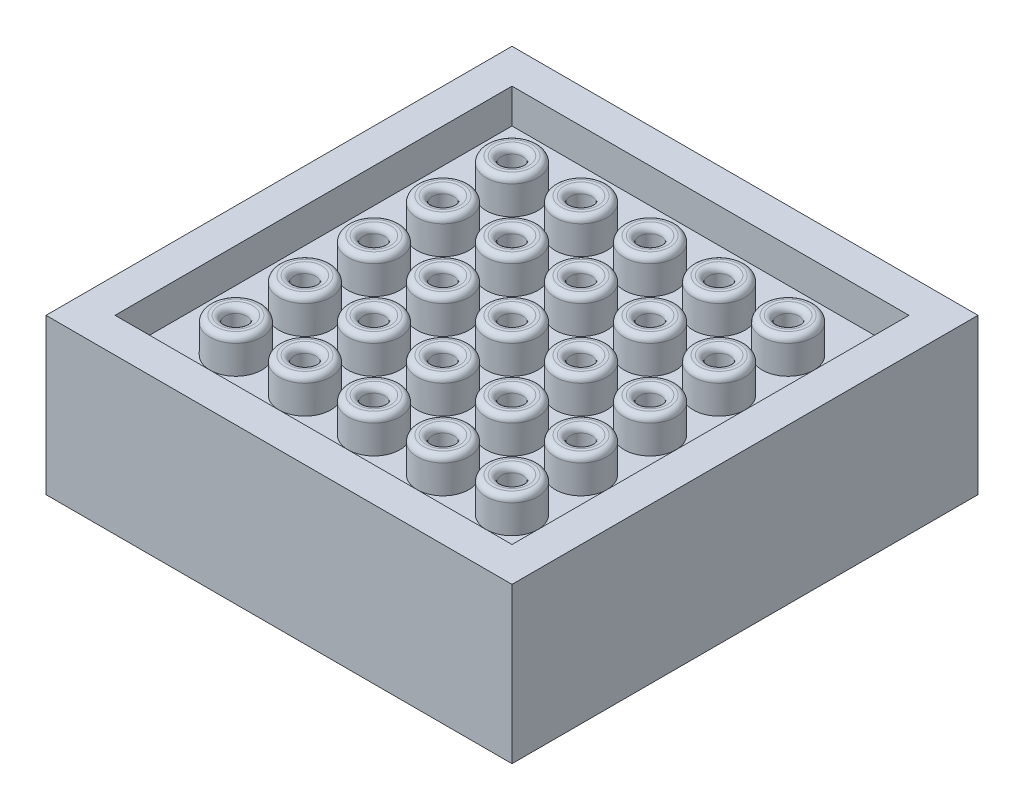
from build123d import *

# Parameters (mm, degrees)
SKETCH1_W              = 27
SKETCH1_H              = 27
SKETCH1_W_2            = 23
SKETCH1_H_2            = 23
BOSS_EXTRUDE1_DEPTH    = 2
SKETCH2_W              = 27
SKETCH2_H              = 27
BOSS_EXTRUDE2_DEPTH    = 2
SKETCH3_W              = 27
SKETCH3_H              = 27
SKETCH3_W_2            = 23
SKETCH3_H_2            = 23
BOSS_EXTRUDE3_DEPTH    = 5
SKETCH6_R              = 1.5
BOSS_EXTRUDE5_DEPTH    = 2
SKETCH7_R              = 0.625
CUT_EXTRUDE2_DEPTH     = 4
FILLET3_R              = 0.35
LPATTERN1_COUNT        = 5
LPATTERN1_PITCH        = 4
LPATTERN1_COUNT_DIR2   = 5
LPATTERN1_PITCH_DIR2   = 4
FILLET3_OF_LPATTERN1_R = 0.35


with BuildPart() as part:
    # Sketch1 → Boss-Extrude1 (new body)
    with BuildSketch(Plane(origin=(0, 0, 0), x_dir=(1, 0, 0), z_dir=(0, 1, 0))):
        Rectangle(SKETCH1_W, SKETCH1_H)
        Rectangle(SKETCH1_W_2, SKETCH1_H_2, mode=Mode.SUBTRACT)
    extrude(amount=BOSS_EXTRUDE1_DEPTH)

    # Sketch2 → Boss-Extrude2 (add)
    with BuildSketch(Plane.XZ):
        Rectangle(SKETCH2_W, SKETCH2_H)
    extrude(amount=BOSS_EXTRUDE2_DEPTH)

    # Sketch3 → Boss-Extrude3 (add)
    with BuildSketch(Plane.XZ.offset(2)):
        Rectangle(SKETCH3_W, SKETCH3_H)
        Rectangle(SKETCH3_W_2, SKETCH3_H_2, mode=Mode.SUBTRACT)
    extrude(amount=BOSS_EXTRUDE3_DEPTH)

    # Sketch6 → Boss-Extrude5 (add)
    with BuildSketch(Plane(origin=(0, 0, 0), x_dir=(1, 0, 0), z_dir=(0, 1, 0))):
        with Locations((8, 8)):
            Circle(SKETCH6_R)
    boss_extrude5 = extrude(amount=BOSS_EXTRUDE5_DEPTH)

    # Sketch7 → Cut-Extrude2 (cut)
    with BuildSketch(Plane(origin=(0, 2, 0), x_dir=(1, 0, 0), z_dir=(0, 1, 0))):
        with Locations((8, 8)):
            Circle(SKETCH7_R)
    cut_extrude2 = extrude(amount=-CUT_EXTRUDE2_DEPTH, mode=Mode.SUBTRACT)

    # Fillet3
    fillet3_edges = [part.edges().sort_by_distance(p)[0] for p in [
        (6.5, 2, -8),
        (7.375, 2, -8),
    ]]
    fillet(fillet3_edges, radius=FILLET3_R)

    # LPattern1: Boss-Extrude5, Cut-Extrude2 5 × 5
    with Locations(*[(-j * LPATTERN1_PITCH_DIR2, 0, i * LPATTERN1_PITCH) for i in range(LPATTERN1_COUNT) for j in range(LPATTERN1_COUNT_DIR2) if (i, j) != (0, 0)]):
        add(boss_extrude5)
        add(cut_extrude2, mode=Mode.SUBTRACT)

    # Fillet3 of LPattern1
    fillet3_of_lpattern1_edges = [part.edges().sort_by_distance(p)[0] for p in [
        (2.5, 2, -8),
        (3.375, 2, -8),
        (-1.5, 2, -8),
        (-0.625, 2, -8),
        (-5.5, 2, -8),
        (-4.625, 2, -8),
        (-9.5, 2, -8),
        (-8.625, 2, -8),
        (6.5, 2, -4),
        (7.375, 2, -4),
        (2.5, 2, -4),
        (3.375, 2, -4),
        (-1.5, 2, -4),
        (-0.625, 2, -4),
        (-5.5, 2, -4),
        (-4.625, 2, -4),
        (-9.5, 2, -4),
        (-8.625, 2, -4),
        (6.5, 2, 0),
        (7.375, 2, 0),
        (2.5, 2, 0),
        (3.375, 2, 0),
        (-1.5, 2, 0),
        (-0.625, 2, 0),
        (-5.5, 2, 0),
        (-4.625, 2, 0),
        (-9.5, 2, 0),
        (-8.625, 2, 0),
        (6.5, 2, 4),
        (7.375, 2, 4),
        (2.5, 2, 4),
        (3.375, 2, 4),
        (-1.5, 2, 4),
        (-0.625, 2, 4),
        (-5.5, 2, 4),
        (-4.625, 2, 4),
        (-9.5, 2, 4),
        (-8.625, 2, 4),
        (6.5, 2, 8),
        (7.375, 2, 8),
        (2.5, 2, 8),
        (3.375, 2, 8),
        (-1.5, 2, 8),
        (-0.625, 2, 8),
        (-5.5, 2, 8),
        (-4.625, 2, 8),
        (-9.5, 2, 8),
        (-8.625, 2, 8),
    ]]
    fillet(fillet3_of_lpattern1_edges, radius=FILLET3_OF_LPATTERN1_R)


solid = part.part
